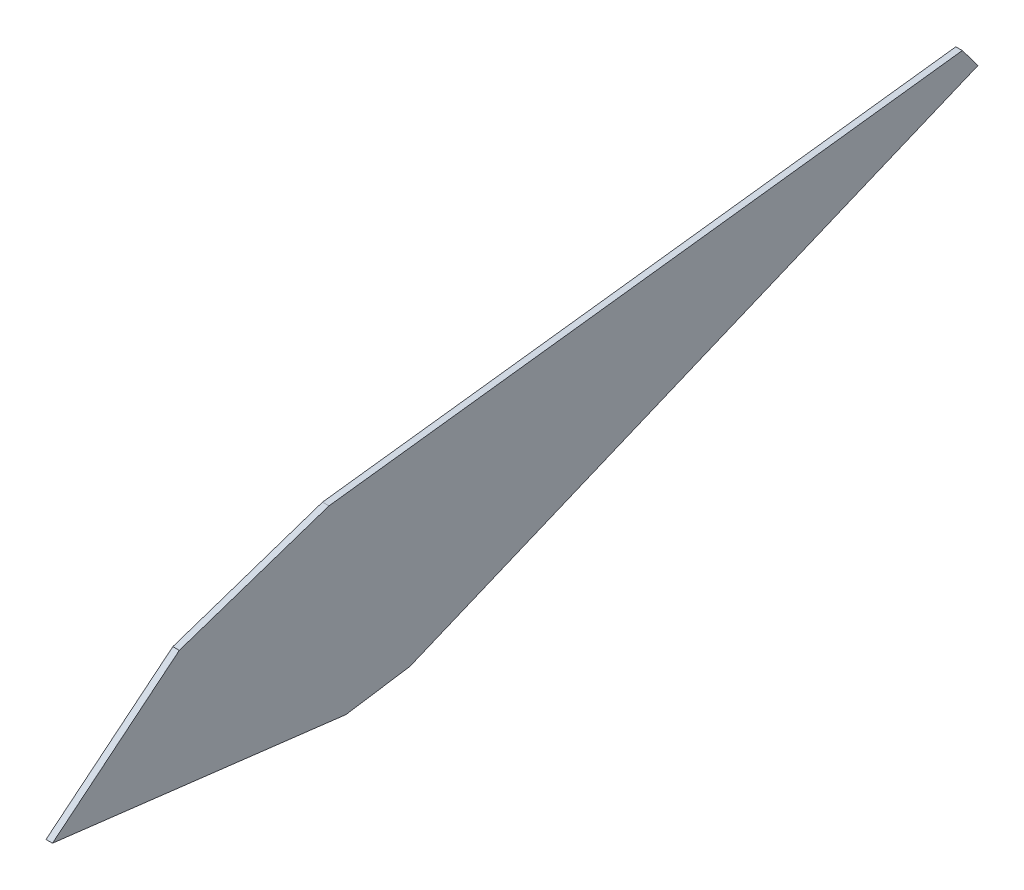
from build123d import *

# Parameters (mm, degrees)
BOSS_EXTRUDE1_DEPTH = 0.635


with BuildPart() as part:
    # Sketch1 → Boss-Extrude1 (new body)
    with BuildSketch(Plane(origin=(0, 0, 0), x_dir=(0, 0, -1), z_dir=(1, 0, 0))):
        Polygon((25.4, 5.715), (23.86076, 7.75716), (-38.24986, 0.1397), (-52.93106, -4.79552), (-65.36944, -14.95552), (-36.58616, -18.42262), (-30.30982, -17.46504), align=None)
    extrude(amount=BOSS_EXTRUDE1_DEPTH)


solid = part.part
